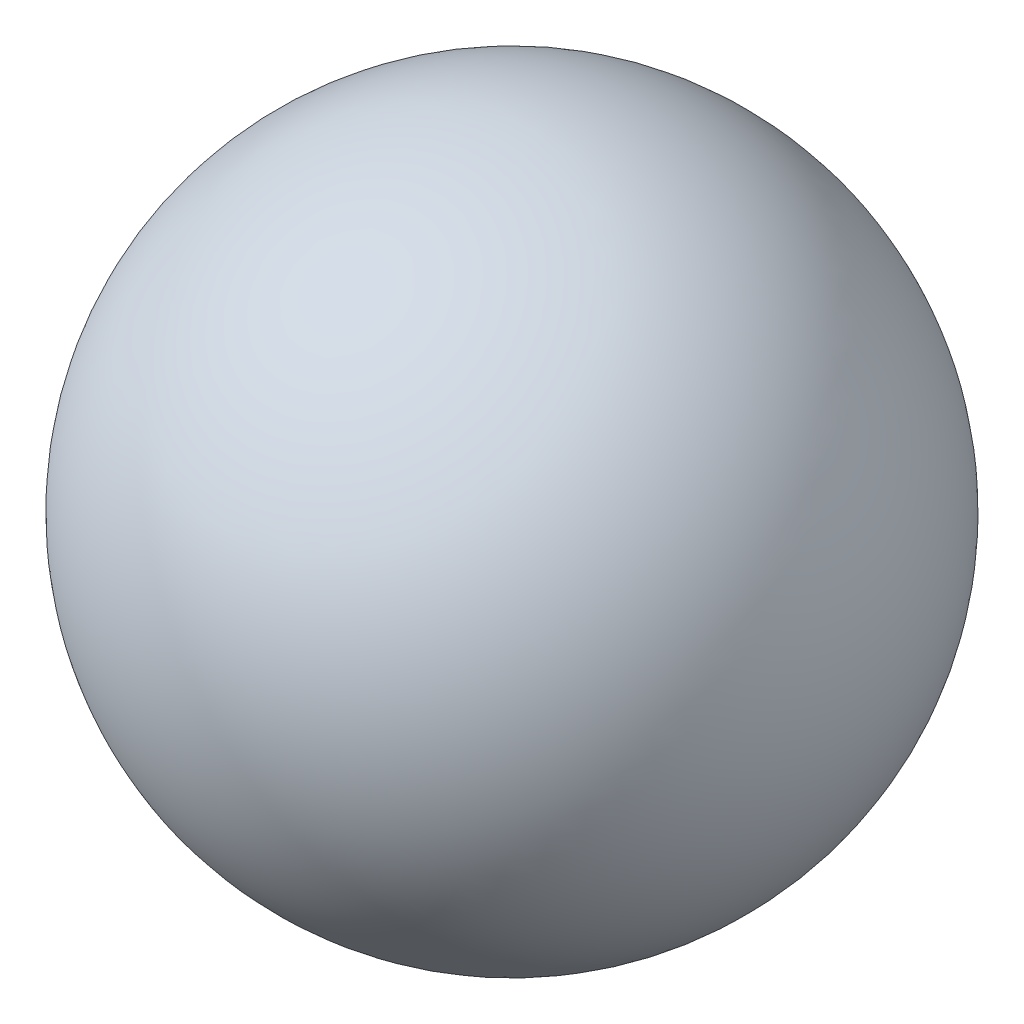
from build123d import *


with BuildPart() as part:
    # Sketch1 → Revolve1 (revolve)
    with BuildSketch(Plane(origin=(0, 0, 0), x_dir=(1, 0, 0), z_dir=(0, 1, 0))):
        with BuildLine():
            Line((0, 2.9), (0, -2.9))
            ThreePointArc((0, -2.9), (-2.9, 0), (0, 2.9))
        make_face()
    revolve(axis=Axis((0, 0, 0), (0, 0, 1)))


solid = part.part
